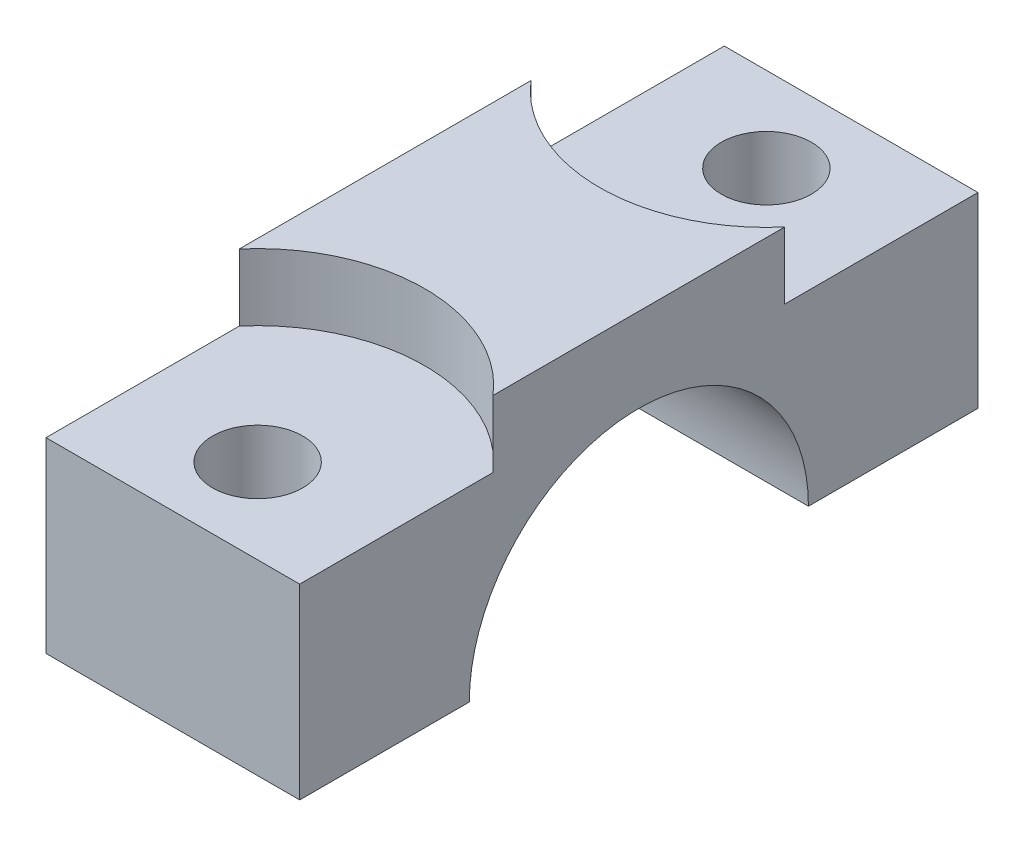
from build123d import *

# Parameters (mm, degrees)
BOSS_EXTRUDE1_DEPTH                           = 9.5
CBORE_FOR_M12_HEX_HEAD_CAP_SCREW1_D           = 6.75
CBORE_FOR_M12_HEX_HEAD_CAP_SCREW1_CBORE_D     = 25
CBORE_FOR_M12_HEX_HEAD_CAP_SCREW1_CBORE_DEPTH = 5


with BuildPart() as part:
    # Sketch1 → Boss-Extrude1 (new body, symmetric)
    with BuildSketch(Plane(origin=(0, 0, 0), x_dir=(0, 0, -1), z_dir=(1, 0, 0))):
        with BuildLine():
            ThreePointArc((-12.7, 0), (0, 12.7), (12.7, 0))
            Line((12.7, 0), (25.4, 0))
            Line((25.4, 0), (25.4, 19))
            Line((25.4, 19), (-25.4, 19))
            Line((-25.4, 19), (-25.4, 0))
            Line((-25.4, 0), (-12.7, 0))
        make_face()
    extrude(amount=BOSS_EXTRUDE1_DEPTH, both=True)

    # CBORE for M12 Hex Head Cap Screw1 (through all)
    with Locations(Plane(origin=(0, 19, -19.05), x_dir=(0, 0, 1), z_dir=(0, 1, 0))):
        with Locations((0, 0), (38.1, 0)):
            CounterBoreHole(CBORE_FOR_M12_HEX_HEAD_CAP_SCREW1_D / 2, CBORE_FOR_M12_HEX_HEAD_CAP_SCREW1_CBORE_D / 2, CBORE_FOR_M12_HEX_HEAD_CAP_SCREW1_CBORE_DEPTH)


solid = part.part
